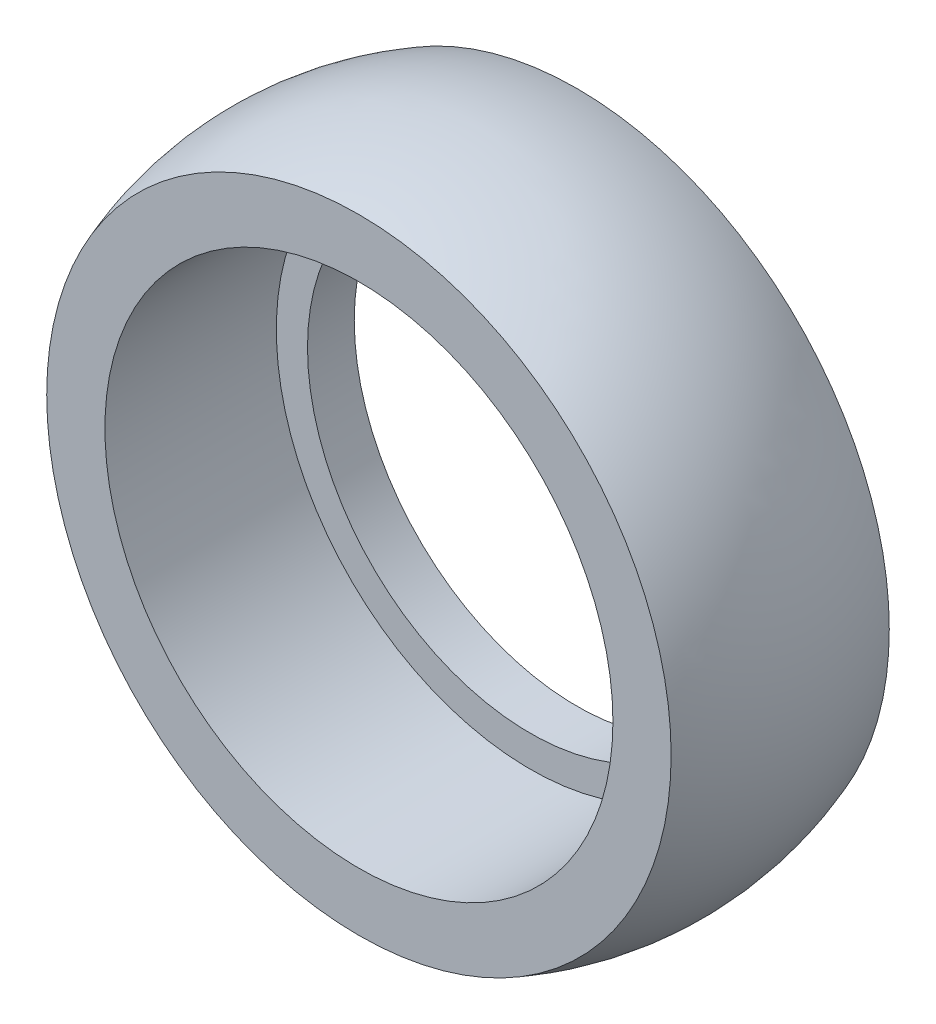
from build123d import *


with BuildPart() as part:
    # Sketch2 → Revolve1 (revolve)
    with BuildSketch(Plane(origin=(0, 0, 0), x_dir=(0, 0, -1), z_dir=(1, 0, 0))):
        with BuildLine():
            Line((-7, 10.017496998), (-7, 8.15))
            Line((-7, 8.15), (-1.5, 8.15))
            Line((-1.5, 8.15), (-1.5, 7.15))
            Line((-1.5, 7.15), (0, 7.15))
            Line((0, 7.15), (0, 10.017496998))
            ThreePointArc((0, 10.017496998), (-3.5, 10.65), (-7, 10.017496998))
        make_face()
    revolve(axis=Axis((0, 0, 0), (0, 0, -1)))


solid = part.part
